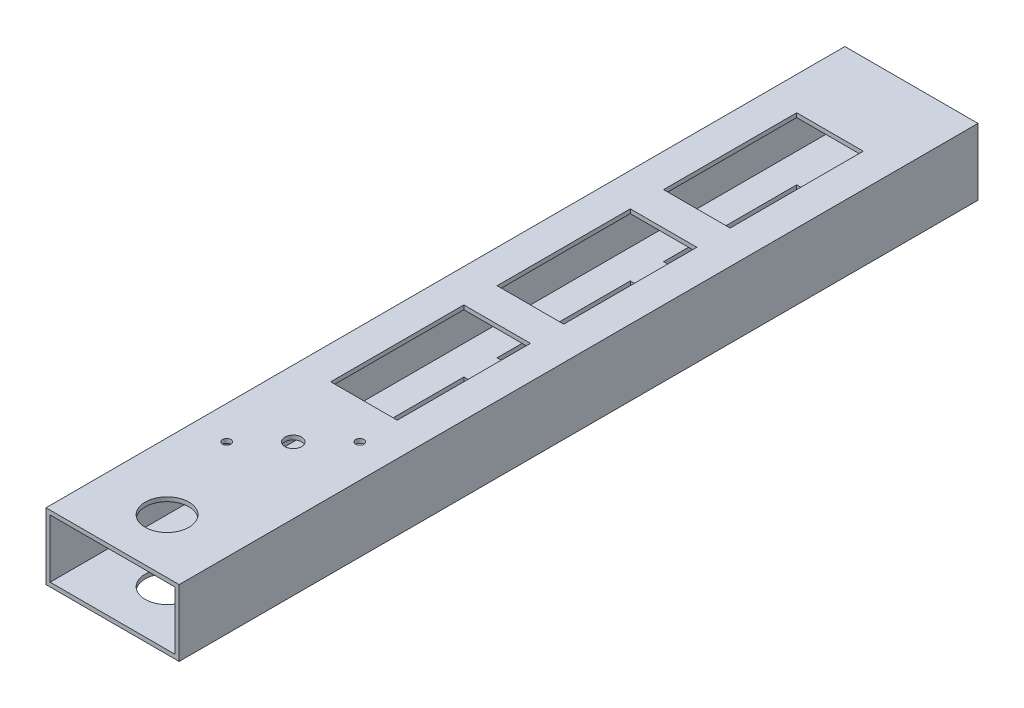
from build123d import *

# Parameters (mm, degrees)
SKETCH1_W           = 50.8
SKETCH1_H           = 25.4
SKETCH1_W_2         = 47.625
SKETCH1_H_2         = 22.225
BOSS_EXTRUDE1_DEPTH = 304.8
SKETCH3_R           = 8.346891379
SKETCH3_R_2         = 3.175
SKETCH3_R_3         = 1.5875
SKETCH3_W           = 25.4
SKETCH3_H           = 50.8
CUT_EXTRUDE2_DEPTH  = 25.4


with BuildPart() as part:
    # Sketch1 → Boss-Extrude1 (new body)
    with BuildSketch(Plane.XY):
        Rectangle(SKETCH1_W, SKETCH1_H)
        Rectangle(SKETCH1_W_2, SKETCH1_H_2, mode=Mode.SUBTRACT)
    extrude(amount=BOSS_EXTRUDE1_DEPTH)

    # Sketch3 → Cut-Extrude2 (cut)
    with BuildSketch(Plane(origin=(0, 12.7, 0), x_dir=(1, 0, 0), z_dir=(0, 1, 0))):
        with Locations((0, -283.999565344)):
            Circle(SKETCH3_R)
        with Locations((0, -235.857473267)):
            Circle(SKETCH3_R_2)
        with Locations((-12.7, -248.557473267)):
            Circle(SKETCH3_R_3)
        with Locations((12.7, -223.157473267)):
            Circle(SKETCH3_R_3)
        with Locations((0, -183.469973267)):
            Rectangle(SKETCH3_W, SKETCH3_H)
        with Locations((0, -119.969973267)):
            Rectangle(SKETCH3_W, SKETCH3_H)
        with Locations((0, -56.469973267)):
            Rectangle(SKETCH3_W, SKETCH3_H)
    extrude(amount=-CUT_EXTRUDE2_DEPTH, mode=Mode.SUBTRACT)


solid = part.part
